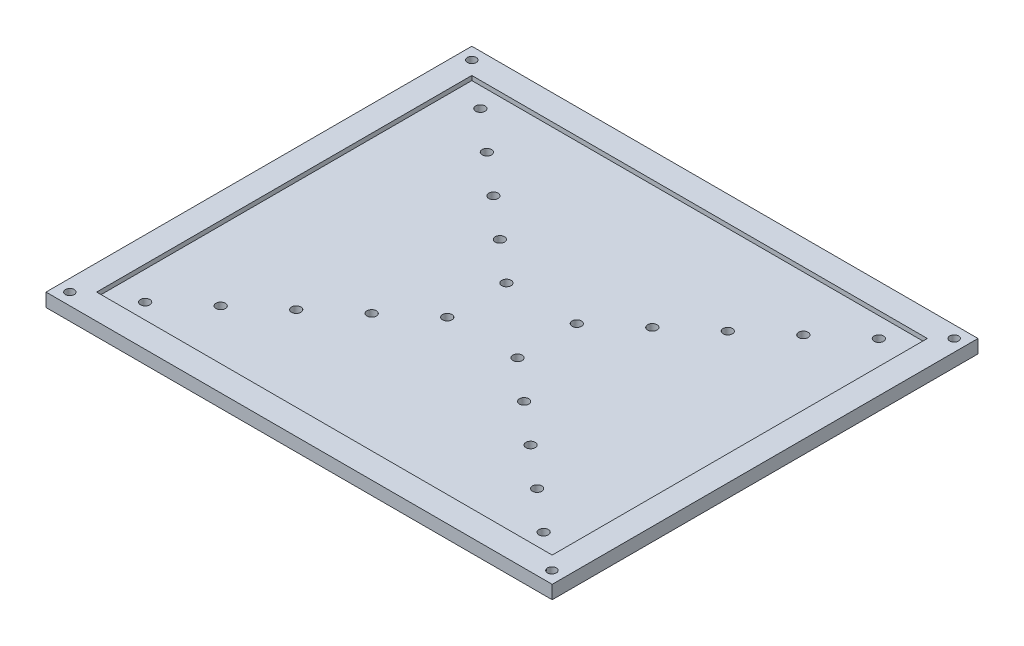
from build123d import *

# Parameters (mm, degrees)
SKETCH1_W           = 188.9
SKETCH1_H           = 158.9
BOSS_EXTRUDE1_DEPTH = 5
SKETCH2_W           = 170
SKETCH2_H           = 140
CUT_EXTRUDE1_DEPTH  = 1.66
SKETCH3_R           = 1.65
CUT_EXTRUDE2_DEPTH  = 5
SKETCH6_R           = 1.65
CUT_EXTRUDE4_DEPTH  = 10
SKETCH7_R           = 1.75
CUT_EXTRUDE5_DEPTH  = 10


with BuildPart() as part:
    # Sketch1 → Boss-Extrude1 (new body)
    with BuildSketch(Plane(origin=(0, 0, 0), x_dir=(1, 0, 0), z_dir=(0, 1, 0))):
        Rectangle(SKETCH1_W, SKETCH1_H)
    extrude(amount=BOSS_EXTRUDE1_DEPTH)

    # Sketch2 → Cut-Extrude1 (cut)
    with BuildSketch(Plane(origin=(0, 5, 0), x_dir=(1, 0, 0), z_dir=(0, 1, 0))):
        Rectangle(SKETCH2_W, SKETCH2_H)
    extrude(amount=-CUT_EXTRUDE1_DEPTH, mode=Mode.SUBTRACT)

    # Sketch3 → Cut-Extrude2 (cut)
    with BuildSketch(Plane(origin=(0, 5, 0), x_dir=(1, 0, 0), z_dir=(0, 1, 0))):
        with Locations((-90, 75)):
            Circle(SKETCH3_R)
    extrude(amount=-CUT_EXTRUDE2_DEPTH, mode=Mode.SUBTRACT)

    # Sketch6 → Cut-Extrude4 (cut)
    with BuildSketch(Plane(origin=(0, 5, 0), x_dir=(1, 0, 0), z_dir=(0, 1, 0))):
        with Locations((-90, -75)):
            Circle(SKETCH6_R)
        with Locations((89.9, -75)):
            Circle(SKETCH6_R)
        with Locations((90, 75)):
            Circle(SKETCH6_R)
    extrude(amount=-CUT_EXTRUDE4_DEPTH, mode=Mode.SUBTRACT)

    # Sketch7 → Cut-Extrude5 (cut)
    with BuildSketch(Plane(origin=(0, 3.34, 0), x_dir=(1, 0, 0), z_dir=(0, 1, 0))):
        with Locations((-74.352299287, 62.544099294)):
            Circle(SKETCH7_R)
        with Locations((74.352299287, -62.544099294)):
            Circle(SKETCH7_R)
        with Locations((-59.047144008, 49.669619814)):
            Circle(SKETCH7_R)
        with Locations((-43.741988729, 36.795140334)):
            Circle(SKETCH7_R)
        with Locations((-28.43683345, 23.920660853)):
            Circle(SKETCH7_R)
        with Locations((-13.131678171, 11.046181373)):
            Circle(SKETCH7_R)
        with Locations((13.131678171, 11.046181373)):
            Circle(SKETCH7_R)
        with Locations((28.43683345, 23.920660853)):
            Circle(SKETCH7_R)
        with Locations((43.741988729, 36.795140334)):
            Circle(SKETCH7_R)
        with Locations((59.047144008, 49.669619814)):
            Circle(SKETCH7_R)
        with Locations((74.352299287, 62.544099294)):
            Circle(SKETCH7_R)
        with Locations((59.047144008, -49.669619814)):
            Circle(SKETCH7_R)
        with Locations((43.741988729, -36.795140334)):
            Circle(SKETCH7_R)
        with Locations((28.43683345, -23.920660853)):
            Circle(SKETCH7_R)
        with Locations((13.131678171, -11.046181373)):
            Circle(SKETCH7_R)
        with Locations((-13.131678171, -11.046181373)):
            Circle(SKETCH7_R)
        with Locations((-28.43683345, -23.920660853)):
            Circle(SKETCH7_R)
        with Locations((-43.741988729, -36.795140334)):
            Circle(SKETCH7_R)
        with Locations((-59.047144008, -49.669619814)):
            Circle(SKETCH7_R)
        with Locations((-74.352299287, -62.544099294)):
            Circle(SKETCH7_R)
    extrude(amount=-CUT_EXTRUDE5_DEPTH, mode=Mode.SUBTRACT)


solid = part.part
